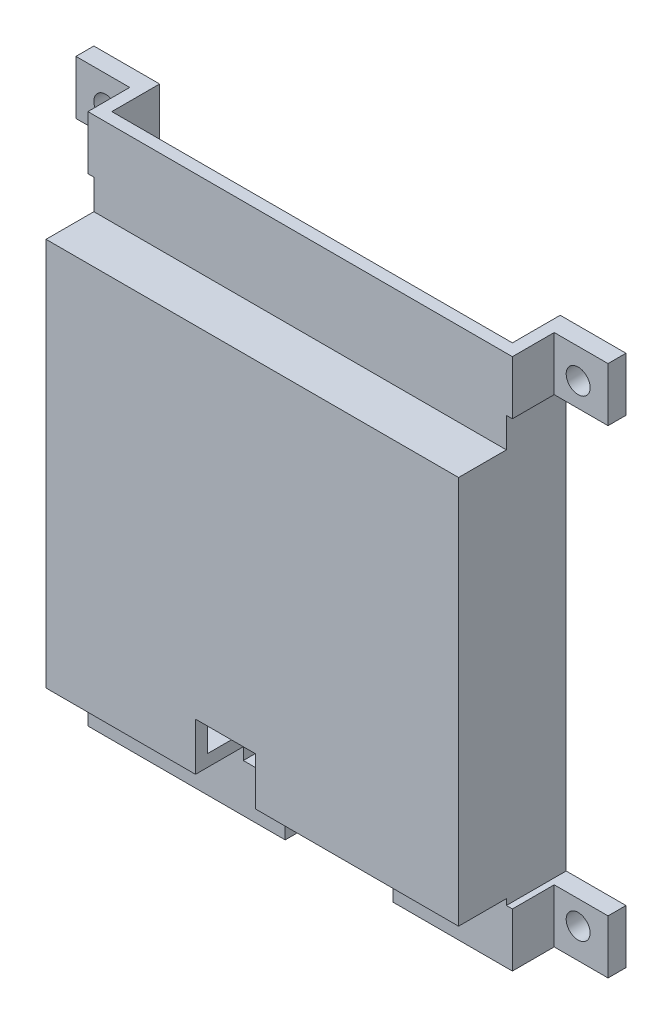
from build123d import *

# Parameters (mm, degrees)
ESQUISSE1_W                  = 89
ESQUISSE1_H                  = 89
MAIN_EXTRUSION_DEPTH         = 18
ESQUISSE2_R                  = 2
FIXATION_HOLE_DEPTH          = 19
ESQUISSE3_W                  = 9
ESQUISSE3_H                  = 9
FIXATION_SQUARE_DEPTH        = 15
CPU_RJ11_DEPTH               = 16
ESQUISSE5_W                  = 10
ESQUISSE5_H                  = 71
ENL_V_MAT_EXTRU_4_DEPTH      = 19
ESQUISSE6_W                  = 67
ESQUISSE6_H                  = 14
ESQUISSE6_W_2                = 16
ESQUISSE6_H_2                = 11
ESQUISSE6_W_3                = 29
HE10_CONNECTORS_DEPTH        = 8
ESQUISSE7_W                  = 8
ESQUISSE7_H                  = 14
ESQUISSE7_H_2                = 10
HE10_CONNECTORS_TOP_DEPTH    = 81
ESQUISSE9_W                  = 10
ESQUISSE9_H                  = 10
ENL_V_MAT_EXTRU_7_DEPTH      = 1
ENL_V_MAT_EXTRU_7_DEPTH_BACK = 19


with BuildPart() as part:
    # Esquisse1 → Main Extrusion (new body)
    with BuildSketch(Plane.XY):
        Rectangle(ESQUISSE1_W, ESQUISSE1_H)
    extrude(amount=MAIN_EXTRUSION_DEPTH)

    # Esquisse2 → Fixation Hole (cut, through all)
    with BuildSketch(Plane.XY.offset(18)):
        with Locations((-39.5, 39.5)):
            Circle(ESQUISSE2_R)
        with Locations((39.5, 39.5)):
            Circle(ESQUISSE2_R)
        with Locations((39.5, -39.5)):
            Circle(ESQUISSE2_R)
        with Locations((-39.5, -39.5)):
            Circle(ESQUISSE2_R)
    extrude(amount=-FIXATION_HOLE_DEPTH, mode=Mode.SUBTRACT)

    # Esquisse3 → Fixation Square (cut)
    with BuildSketch(Plane.XY.offset(18)):
        with Locations((-40, 40)):
            Rectangle(ESQUISSE3_W, ESQUISSE3_H)
        with Locations((-40, -40)):
            Rectangle(ESQUISSE3_W, ESQUISSE3_H)
        with Locations((40, -40)):
            Rectangle(ESQUISSE3_W, ESQUISSE3_H)
        with Locations((40, 40)):
            Rectangle(ESQUISSE3_W, ESQUISSE3_H)
    extrude(amount=-FIXATION_SQUARE_DEPTH, mode=Mode.SUBTRACT)

    # Esquisse4 → CPU + RJ11 (cut)
    with BuildSketch(Plane(origin=(0, 0, 0), x_dir=(-1, 0, 0), z_dir=(0, 0, -1))):
        Polygon((-32.5, -32.5), (-15.5, -32.5), (-15.5, -44.5), (2.5, -44.5), (2.5, -32.5), (32.5, -32.5), (32.5, 28.5), (-32.5, 28.5), align=None)
    extrude(amount=-CPU_RJ11_DEPTH, mode=Mode.SUBTRACT)

    # Esquisse5 → Enlèv. mat.-Extru.4 (cut, through all)
    with BuildSketch(Plane.XY.offset(18)):
        with Locations((-39.5, 0)):
            Rectangle(ESQUISSE5_W, ESQUISSE5_H)
        with Locations((39.5, 0)):
            Rectangle(ESQUISSE5_W, ESQUISSE5_H)
    extrude(amount=-ENL_V_MAT_EXTRU_4_DEPTH, mode=Mode.SUBTRACT)

    # Esquisse6 → HE10 Connectors (cut)
    with BuildSketch(Plane(origin=(0, 0, 0), x_dir=(-1, 0, 0), z_dir=(0, 0, -1))):
        with Locations((0, 37.5)):
            Rectangle(ESQUISSE6_W, ESQUISSE6_H)
        with Locations((-25.5, -39)):
            Rectangle(ESQUISSE6_W_2, ESQUISSE6_H_2)
        with Locations((19, -39)):
            Rectangle(ESQUISSE6_W_3, ESQUISSE6_H_2)
    extrude(amount=-HE10_CONNECTORS_DEPTH, mode=Mode.SUBTRACT)

    # Esquisse7 → HE10 Connectors Top (cut, through all)
    with BuildSketch(Plane.ZY.offset(35.5)):
        with Locations((14, 37.5)):
            Rectangle(ESQUISSE7_W, ESQUISSE7_H)
        with Locations((14, -39.5)):
            Rectangle(ESQUISSE7_W, ESQUISSE7_H_2)
    extrude(amount=-HE10_CONNECTORS_TOP_DEPTH, mode=Mode.SUBTRACT)

    # Esquisse9 → Enlèv. mat.-Extru.7 (cut, two sides)
    with BuildSketch(Plane.XY.offset(18)) as enl_v_mat_extru_7_sk:
        with Locations((-4.5, -31.5)):
            Rectangle(ESQUISSE9_W, ESQUISSE9_H)
    extrude(amount=ENL_V_MAT_EXTRU_7_DEPTH, mode=Mode.SUBTRACT)
    extrude(enl_v_mat_extru_7_sk.sketch, amount=-ENL_V_MAT_EXTRU_7_DEPTH_BACK, mode=Mode.SUBTRACT)


solid = part.part
